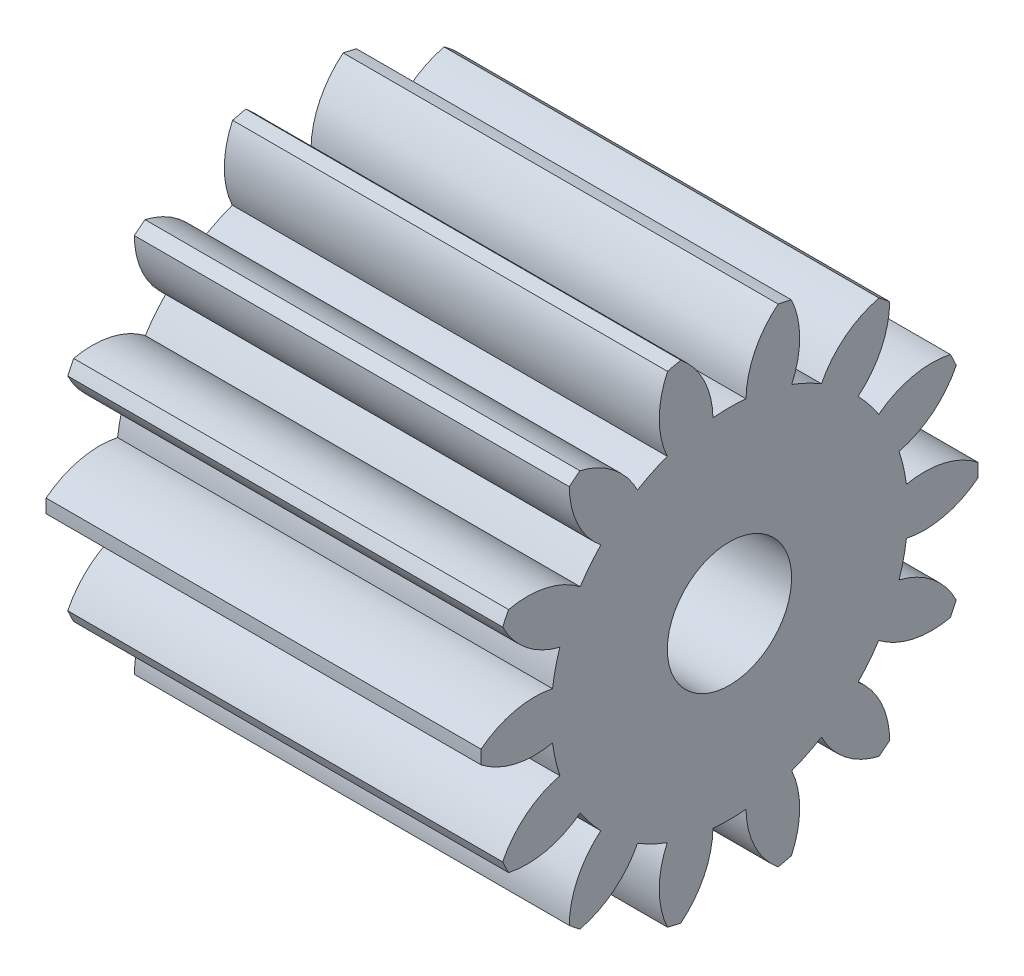
from build123d import *

# Parameters (mm, degrees)
BASPROSKE_W     = 3.5
BASPROSKE_H     = 2
TOOTHCUT_DEPTH  = 5.5
TEETHCUTS_COUNT = 14
TEETHCUTS_ANGLE = 334.285714286
BORSKE_R        = 0.5
BORE_DEPTH      = 50.0000508


with BuildPart() as part:
    # BasProSke → Base-Revolve (revolve)
    with BuildSketch(Plane(origin=(0, 0, 0), x_dir=(1, 0, 0), z_dir=(0, 1, 0)), mode=Mode.PRIVATE) as base_revolve_sk:
        with Locations((1.75, 1)):
            Rectangle(BASPROSKE_W, BASPROSKE_H)
    revolve(base_revolve_sk.sketch.rotate(Axis((-10, 0, 0), (1, 0, 0)), 180), axis=Axis((-10, 0, 0), (1, 0, 0)))

    # TooCutSke → ToothCut (cut, through all)
    with BuildSketch(Plane(origin=(0, 0, 0), x_dir=(0, 0, -1), z_dir=(1, 0, 0))):
        with BuildLine():
            ThreePointArc((0.132926628, 1.43033659), (0, 1.4365), (-0.132926628, 1.43033659))
            ThreePointArc((-0.132926628, 1.43033659), (-0.210971396, 1.739395683), (-0.417964864, 1.981804867))
            ThreePointArc((-0.417964864, 1.981804867), (0, 2.0254), (0.417964864, 1.981804867))
            ThreePointArc((0.417964864, 1.981804867), (0.210971396, 1.739395683), (0.132926628, 1.43033659))
        make_face()
    toothcut = extrude(amount=TOOTHCUT_DEPTH, mode=Mode.SUBTRACT)

    # TeethCuts: ToothCut ×14 about axis
    teethcuts_axis = Axis((-10, 0, 0), (1, 0, 0))
    for i in range(1, TEETHCUTS_COUNT):
        add(toothcut.rotate(teethcuts_axis, i * TEETHCUTS_ANGLE / (TEETHCUTS_COUNT - 1)), mode=Mode.SUBTRACT)

    # BorSke → Bore (cut, symmetric)
    with BuildSketch(Plane(origin=(0, 0, 0), x_dir=(0, 0, -1), z_dir=(1, 0, 0))):
        with Locations(Location((0, 0, 0), (0, 0, 180))):
            Circle(BORSKE_R)
    extrude(amount=BORE_DEPTH, both=True, mode=Mode.SUBTRACT)


solid = part.part
